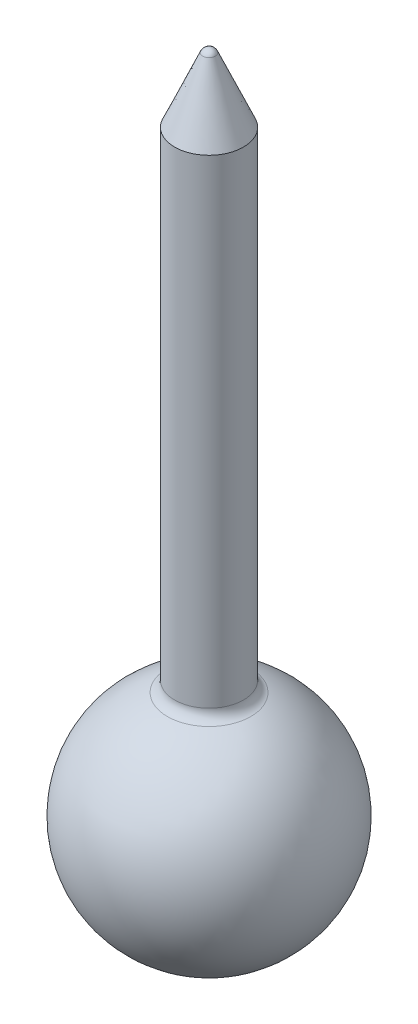
from build123d import *


with BuildPart() as part:
    # Эскиз1 → Повернуть1 (revolve)
    with BuildSketch(Plane.XY):
        with BuildLine():
            Line((1.5, 31), (0.27515818, 33.819532322))
            ThreePointArc((0.27515818, 33.819532322), (0.164530094, 33.950858224), (0, 34))
            Line((0, 34), (0, 32))
            ThreePointArc((0, 32), (0.353553391, 31.853553391), (0.5, 31.5))
            Line((0.5, 31.5), (0.5, 10.153882032))
            ThreePointArc((0.5, 10.153882032), (0.614241625, 9.835777527), (0.904761905, 9.663036124))
            ThreePointArc((0.904761905, 9.663036124), (4.728209047, 4.545534154), (0, 0.25))
            Line((0, 0.25), (0, 0))
            ThreePointArc((0, 0), (4.913681129, 4.074939047), (1.818181818, 9.657704894))
            ThreePointArc((1.818181818, 9.657704894), (1.587138588, 9.841437346), (1.5, 10.123475383))
            Line((1.5, 10.123475383), (1.5, 31))
        make_face()
    revolve(axis=Axis((0, 0, 0), (0, 1, 0)))


solid = part.part
